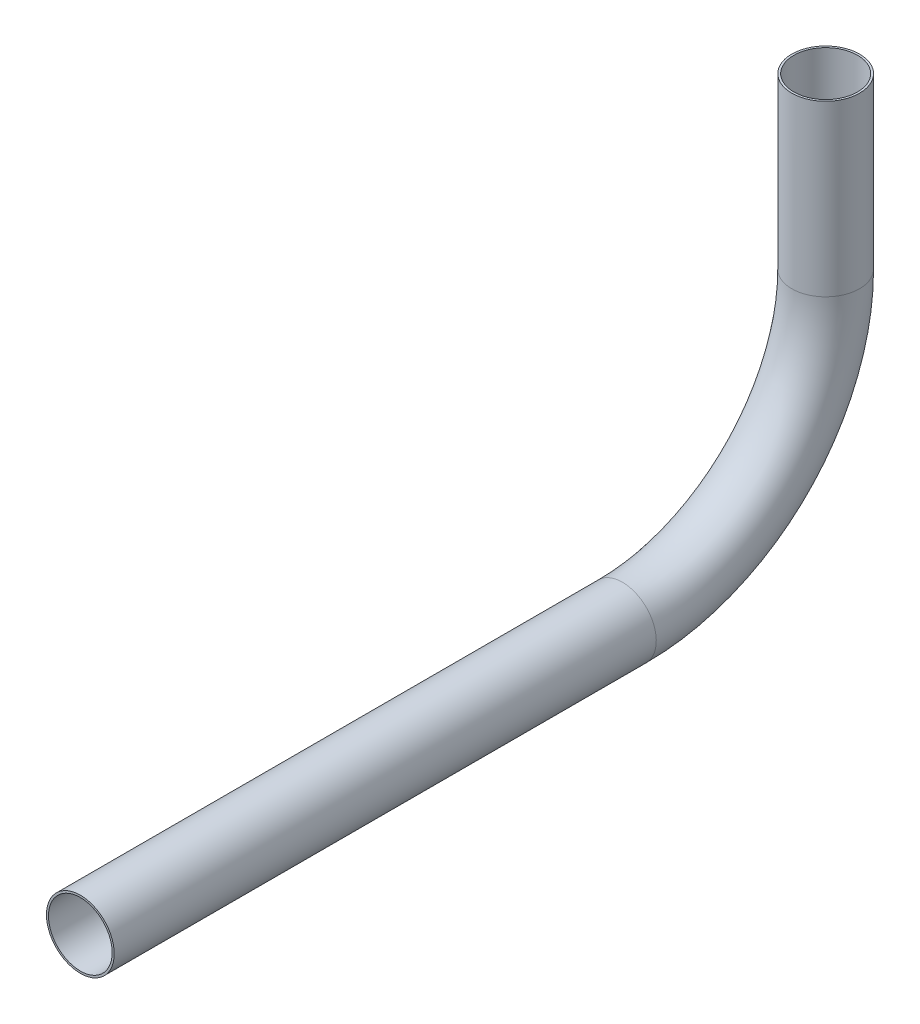
from build123d import *

# Parameters (mm, degrees)
SKETCH1_R   = 6.35
SKETCH1_R_2 = 5.969


with BuildPart() as part:
    # Sweep1: sweep along a path in Sketch2
    with BuildLine(Plane(origin=(0, 0, 0), x_dir=(0, 0, -1), z_dir=(1, 0, 0))) as sweep1_path:
        Line((0, 0), (0, -31.75))
        ThreePointArc((0, -31.75), (-11.159231637, -58.690768363), (-38.1, -69.85))
        Line((-38.1, -69.85), (-139.7, -69.85))
    # Sketch1 → Sweep1 (sweep)
    with BuildSketch(Plane(origin=(0, 0, 0), x_dir=(1, 0, 0), z_dir=(0, 1, 0))):
        Circle(SKETCH1_R)
        Circle(SKETCH1_R_2, mode=Mode.SUBTRACT)
    sweep(path=sweep1_path.line)


solid = part.part
